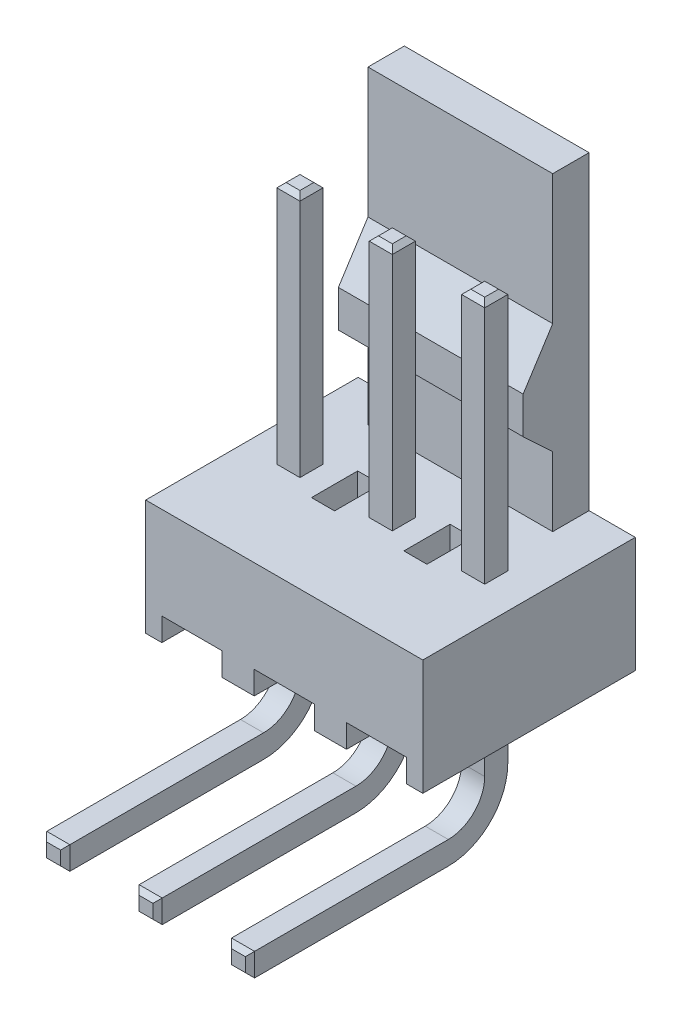
from build123d import *

# Parameters (mm, degrees)
SKETCH1_W            = 6.35
SKETCH1_H            = 5.842
BOSS_EXTRUDE1_DEPTH  = 3.175
BOSS_EXTRUDE2_DEPTH  = 5.08
SKETCH3_W            = 5.842
SKETCH3_H            = 3.175
BOSS_EXTRUDE3_DEPTH  = 1.27
SKETCH4_W            = 1.651
SKETCH4_H            = 0.635
CUT_EXTRUDE1_DEPTH   = 6.842
SKETCH5_W            = 0.635
SKETCH5_H            = 0.635
BOSS_EXTRUDE4_DEPTH  = 3.6725
SKETCH6_W            = 0.635
SKETCH6_H            = 0.635
BOSS_EXTRUDE5_DEPTH  = 6.4543
SKETCH7_W            = 1.651
SKETCH7_H            = 0.635
CUT_EXTRUDE2_DEPTH   = 10.642
SKETCH8_W            = 0.635
SKETCH8_H            = 0.635
BOSS_EXTRUDE6_DEPTH  = 3.6725
SKETCH9_W            = 0.635
SKETCH9_H            = 0.635
BOSS_EXTRUDE7_DEPTH  = 6.4543
SKETCH10_W           = 1.651
SKETCH10_H           = 0.635
CUT_EXTRUDE3_DEPTH   = 10.642
SKETCH11_W           = 0.635
SKETCH11_H           = 0.635
BOSS_EXTRUDE8_DEPTH  = 3.6725
SKETCH12_W           = 0.635
SKETCH12_H           = 0.635
BOSS_EXTRUDE9_DEPTH  = 6.4543
SKETCH13_W           = 0.635
SKETCH13_H           = 0.635
BOSS_EXTRUDE10_DEPTH = 6.71
SKETCH14_W           = 0.635
SKETCH14_H           = 0.635
BOSS_EXTRUDE11_DEPTH = 6.71
SKETCH15_W           = 0.635
SKETCH15_H           = 0.635
BOSS_EXTRUDE12_DEPTH = 6.71
SKETCH16_W           = 0.635
SKETCH16_H           = 1.27
CUT_EXTRUDE4_DEPTH   = 1.27
SKETCH17_W           = 0.635
SKETCH17_H           = 1.27
CUT_EXTRUDE5_DEPTH   = 1.27
CHAMFER1_SIZE        = 0.127
CHAMFER2_SIZE        = 0.753913762
CHAMFER2_SIZE2       = 0.55706549
FILLET1_R            = 1
FILLET2_R            = 1.635


with BuildPart() as part:
    # Sketch1 → Boss-Extrude1 (new body)
    with BuildSketch(Plane.XZ.offset(1.5875)):
        with Locations((-0.635, 0.0508)):
            Rectangle(SKETCH1_W, SKETCH1_H)
    extrude(amount=-BOSS_EXTRUDE1_DEPTH)

    # Sketch2 → Boss-Extrude2 (add)
    with BuildSketch(Plane(origin=(2.54, 0, 0), x_dir=(0, 0, -1), z_dir=(1, 0, 0))):
        Polygon((0.651, 4.6355), (1.8702, 3.4925), (1.8702, 1.5875), (2.8702, 1.5875), (2.8702, 10.1125), (1.8702, 10.1125), (1.8702, 6.5405), align=None)
    extrude(amount=-BOSS_EXTRUDE2_DEPTH)

    # Sketch3 → Boss-Extrude3 (add)
    with BuildSketch(Plane(origin=(2.54, 0, 0), x_dir=(0, 0, -1), z_dir=(1, 0, 0))):
        with Locations((-0.0508, 0)):
            Rectangle(SKETCH3_W, SKETCH3_H)
    extrude(amount=BOSS_EXTRUDE3_DEPTH)

    # Sketch4 → Cut-Extrude1 (cut, through all)
    with BuildSketch(Plane(origin=(0, 0, -2.8702), x_dir=(-1, 0, 0), z_dir=(0, 0, -1))):
        with Locations((0, -1.27)):
            Rectangle(SKETCH4_W, SKETCH4_H)
    extrude(amount=-CUT_EXTRUDE1_DEPTH, mode=Mode.SUBTRACT)

    # Sketch5 → Boss-Extrude4 (add)
    with BuildSketch(Plane.XZ.offset(0.9525)):
        Rectangle(SKETCH5_W, SKETCH5_H)
    extrude(amount=BOSS_EXTRUDE4_DEPTH)

    # Sketch6 → Boss-Extrude5 (add)
    with BuildSketch(Plane.XY.offset(0.3175)):
        with Locations((0, -4.3075)):
            Rectangle(SKETCH6_W, SKETCH6_H)
    extrude(amount=BOSS_EXTRUDE5_DEPTH)

    # Sketch7 → Cut-Extrude2 (cut, through all)
    with BuildSketch(Plane(origin=(0, 0, -2.8702), x_dir=(-1, 0, 0), z_dir=(0, 0, -1))):
        with Locations((2.54, -1.27)):
            Rectangle(SKETCH7_W, SKETCH7_H)
    extrude(amount=-CUT_EXTRUDE2_DEPTH, mode=Mode.SUBTRACT)

    # Sketch8 → Boss-Extrude6 (add)
    with BuildSketch(Plane.XZ.offset(0.9525)):
        with Locations((-2.54, 0)):
            Rectangle(SKETCH8_W, SKETCH8_H)
    extrude(amount=BOSS_EXTRUDE6_DEPTH)

    # Sketch9 → Boss-Extrude7 (add)
    with BuildSketch(Plane.XY.offset(0.3175)):
        with Locations((-2.54, -4.3075)):
            Rectangle(SKETCH9_W, SKETCH9_H)
    extrude(amount=BOSS_EXTRUDE7_DEPTH)

    # Sketch10 → Cut-Extrude3 (cut, through all)
    with BuildSketch(Plane(origin=(0, 0, -2.8702), x_dir=(-1, 0, 0), z_dir=(0, 0, -1))):
        with Locations((-2.54, -1.27)):
            Rectangle(SKETCH10_W, SKETCH10_H)
    extrude(amount=-CUT_EXTRUDE3_DEPTH, mode=Mode.SUBTRACT)

    # Sketch11 → Boss-Extrude8 (add)
    with BuildSketch(Plane.XZ.offset(0.9525)):
        with Locations((2.54, 0)):
            Rectangle(SKETCH11_W, SKETCH11_H)
    extrude(amount=BOSS_EXTRUDE8_DEPTH)

    # Sketch12 → Boss-Extrude9 (add)
    with BuildSketch(Plane.XY.offset(0.3175)):
        with Locations((2.54, -4.3075)):
            Rectangle(SKETCH12_W, SKETCH12_H)
    extrude(amount=BOSS_EXTRUDE9_DEPTH)

    # Sketch13 → Boss-Extrude10 (add)
    with BuildSketch(Plane(origin=(0, 1.5875, 0), x_dir=(-1, 0, 0), z_dir=(0, 1, 0))):
        with Locations((-2.54, 0)):
            Rectangle(SKETCH13_W, SKETCH13_H)
    extrude(amount=BOSS_EXTRUDE10_DEPTH)

    # Sketch14 → Boss-Extrude11 (add)
    with BuildSketch(Plane(origin=(0, 1.5875, 0), x_dir=(-1, 0, 0), z_dir=(0, 1, 0))):
        Rectangle(SKETCH14_W, SKETCH14_H)
    extrude(amount=BOSS_EXTRUDE11_DEPTH)

    # Sketch15 → Boss-Extrude12 (add)
    with BuildSketch(Plane(origin=(0, 1.5875, 0), x_dir=(-1, 0, 0), z_dir=(0, 1, 0))):
        with Locations((2.54, 0)):
            Rectangle(SKETCH15_W, SKETCH15_H)
    extrude(amount=BOSS_EXTRUDE12_DEPTH)

    # Sketch16 → Cut-Extrude4 (cut)
    with BuildSketch(Plane(origin=(0, 1.5875, 0), x_dir=(-1, 0, 0), z_dir=(0, 1, 0))):
        with Locations((-1.27, 0)):
            Rectangle(SKETCH16_W, SKETCH16_H)
    extrude(amount=-CUT_EXTRUDE4_DEPTH, mode=Mode.SUBTRACT)

    # Sketch17 → Cut-Extrude5 (cut)
    with BuildSketch(Plane(origin=(0, 1.5875, 0), x_dir=(-1, 0, 0), z_dir=(0, 1, 0))):
        with Locations((1.27, 0)):
            Rectangle(SKETCH17_W, SKETCH17_H)
    extrude(amount=-CUT_EXTRUDE5_DEPTH, mode=Mode.SUBTRACT)

    # Chamfer1
    chamfer1_edges = [part.edges().sort_by_distance(p)[0] for p in [
        (-2.54, -3.99, 6.7718),
        (-2.8575, -4.3075, 6.7718),
        (-2.54, -4.625, 6.7718),
        (-2.2225, -4.3075, 6.7718),
        (2.8575, -4.3075, 6.7718),
        (2.54, -3.99, 6.7718),
        (2.2225, -4.3075, 6.7718),
        (2.54, -4.625, 6.7718),
        (2.2225, 8.2975, 0),
        (2.54, 8.2975, 0.3175),
        (2.8575, 8.2975, 0),
        (2.54, 8.2975, -0.3175),
        (0.3175, 8.2975, 0),
        (0, 8.2975, -0.3175),
        (-0.3175, 8.2975, 0),
        (0, 8.2975, 0.3175),
        (-2.54, 8.2975, 0.3175),
        (-2.2225, 8.2975, 0),
        (-2.54, 8.2975, -0.3175),
        (-2.8575, 8.2975, 0),
        (0, -3.99, 6.7718),
        (-0.3175, -4.3075, 6.7718),
        (0, -4.625, 6.7718),
        (0.3175, -4.3075, 6.7718),
    ]]
    chamfer(chamfer1_edges, length=CHAMFER1_SIZE)

    # Chamfer2
    chamfer2_edges = [part.edges().sort_by_distance(p)[0] for p in [
        (0, 4.6355, -0.651),
    ]]
    chamfer2_side = [part.faces().sort_by_distance(p)[0] for p in [
        (0, 5.588, -1.2606),
    ]]
    chamfer(chamfer2_edges, length=CHAMFER2_SIZE, length2=CHAMFER2_SIZE2, reference=chamfer2_side[0])

    # Fillet1
    fillet1_edges = [part.edges().sort_by_distance(p)[0] for p in [
        (-2.54, -3.99, 0.3175),
        (2.54, -3.99, 0.3175),
        (0, -3.99, 0.3175),
    ]]
    fillet(fillet1_edges, radius=FILLET1_R)

    # Fillet2
    fillet2_edges = [part.edges().sort_by_distance(p)[0] for p in [
        (-2.54, -4.625, -0.3175),
        (2.54, -4.625, -0.3175),
        (0, -4.625, -0.3175),
    ]]
    fillet(fillet2_edges, radius=FILLET2_R)


solid = part.part
